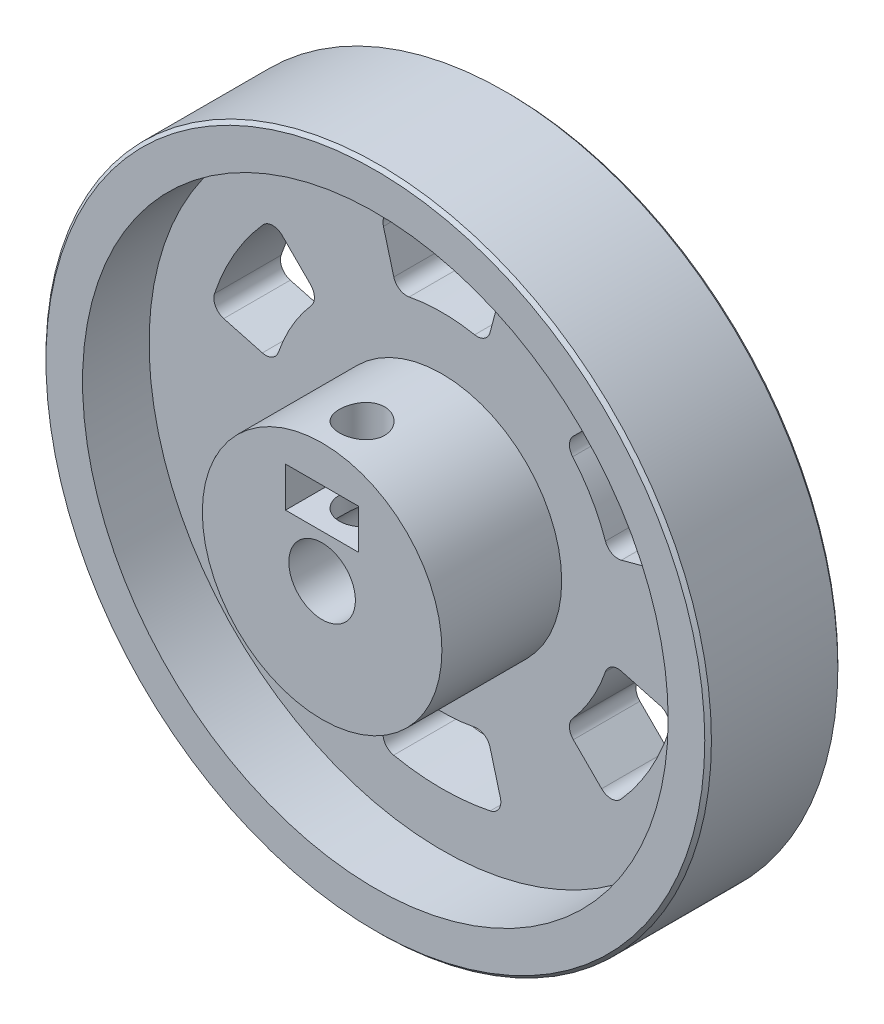
from build123d import *

# Parameters (mm, degrees)
SKETCH1_R           = 25
BOSS_EXTRUDE1_DEPTH = 5
SKETCH3_R           = 25
SKETCH3_R_2         = 22
BOSS_EXTRUDE3_DEPTH = 10
SKETCH4_R           = 9
BOSS_EXTRUDE4_DEPTH = 14
SKETCH5_R           = 2.5
CUT_EXTRUDE1_DEPTH  = 15
SKETCH6_W           = 5.5
SKETCH6_H           = 3
CUT_EXTRUDE2_DEPTH  = 6
CUT_EXTRUDE3_START  = 1.83304
SKETCH7_R           = 1.7
CUT_EXTRUDE3_DEPTH  = 7.16696
CUT_EXTRUDE4_DEPTH  = 15.0000001
CIRPATTERN1_COUNT   = 6
CHAMFER1_SIZE       = 0.25


with BuildPart() as part:
    # Sketch1 → Boss-Extrude1 (new body)
    with BuildSketch(Plane.XY):
        Circle(SKETCH1_R)
    extrude(amount=BOSS_EXTRUDE1_DEPTH)

    # Sketch3 → Boss-Extrude3 (add)
    with BuildSketch(Plane.XY):
        Circle(SKETCH3_R)
        Circle(SKETCH3_R_2, mode=Mode.SUBTRACT)
    extrude(amount=BOSS_EXTRUDE3_DEPTH)

    # Sketch4 → Boss-Extrude4 (add)
    with BuildSketch(Plane.XY):
        Circle(SKETCH4_R)
    extrude(amount=BOSS_EXTRUDE4_DEPTH)

    # Sketch5 → Cut-Extrude1 (cut, through all)
    with BuildSketch(Plane.XY):
        Circle(SKETCH5_R)
    extrude(amount=CUT_EXTRUDE1_DEPTH, mode=Mode.SUBTRACT)

    # Sketch6 → Cut-Extrude2 (cut)
    with BuildSketch(Plane.XY.offset(14)):
        with Locations((0, 4.75)):
            Rectangle(SKETCH6_W, SKETCH6_H)
    extrude(amount=-CUT_EXTRUDE2_DEPTH, mode=Mode.SUBTRACT)

    # Sketch7 → Cut-Extrude3 (cut)
    with BuildSketch(Plane(origin=(0, 0, 0), x_dir=(1, 0, 0), z_dir=(0, 1, 0)).offset(CUT_EXTRUDE3_START)):
        with Locations((0, -11)):
            Circle(SKETCH7_R)
    extrude(amount=CUT_EXTRUDE3_DEPTH, mode=Mode.SUBTRACT)

    # Sketch8 → Cut-Extrude4 (cut, through all)
    with BuildSketch(Plane.XY):
        with BuildLine():
            Line((-4.392304845, 16.392304845), (-3.614211274, 13.488420103))
            ThreePointArc((-3.614211274, 13.488420103), (-3.178915308, 12.899635496), (-2.459122201, 12.765293494))
            ThreePointArc((-2.459122201, 12.765293494), (0, 13), (2.459122201, 12.765293494))
            ThreePointArc((2.459122201, 12.765293494), (3.178915308, 12.899635496), (3.614211274, 13.488420103))
            Line((3.614211274, 13.488420103), (4.392304845, 16.392304845))
            ThreePointArc((4.392304845, 16.392304845), (4.277317186, 17.176389762), (3.627930726, 17.630601766))
            ThreePointArc((3.627930726, 17.630601766), (0, 18), (-3.627930726, 17.630601766))
            ThreePointArc((-3.627930726, 17.630601766), (-4.277317186, 17.176389762), (-4.392304845, 16.392304845))
        make_face()
    cut_extrude4 = extrude(amount=CUT_EXTRUDE4_DEPTH, mode=Mode.SUBTRACT)

    # CirPattern1: Cut-Extrude4 ×6 about axis
    cirpattern1_axis = Axis((0, 0, 0), (0, 0, 1))
    for i in range(1, CIRPATTERN1_COUNT):
        add(cut_extrude4.rotate(cirpattern1_axis, i * 360 / CIRPATTERN1_COUNT), mode=Mode.SUBTRACT)

    # Chamfer1
    chamfer1_edges = [part.edges().sort_by_distance(p)[0] for p in [
        (-25, 0, 0),
        (-25, 0, 10),
    ]]
    chamfer(chamfer1_edges, length=CHAMFER1_SIZE)


solid = part.part
